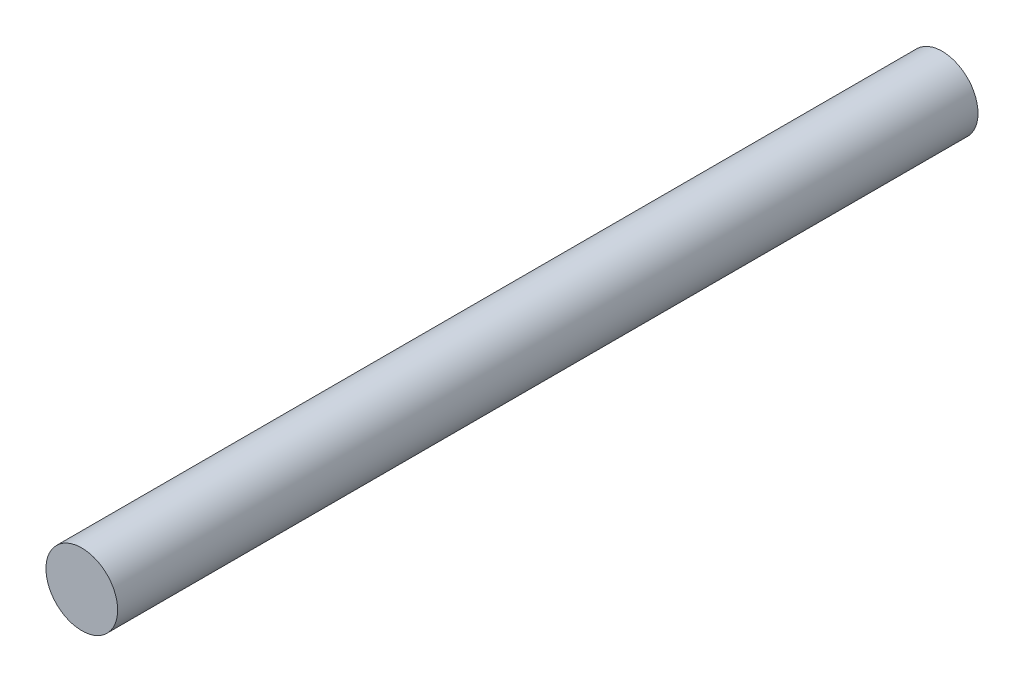
from build123d import *

# Parameters (mm, degrees)
IZIM1_R                     = 5
Y_KSEKLIK_EKSTR_ZYON1_DEPTH = 120


with BuildPart() as part:
    # Çizim1 → Yükseklik-Ekstrüzyon1 (new body)
    with BuildSketch(Plane.XY):
        Circle(IZIM1_R)
    extrude(amount=Y_KSEKLIK_EKSTR_ZYON1_DEPTH)


solid = part.part
